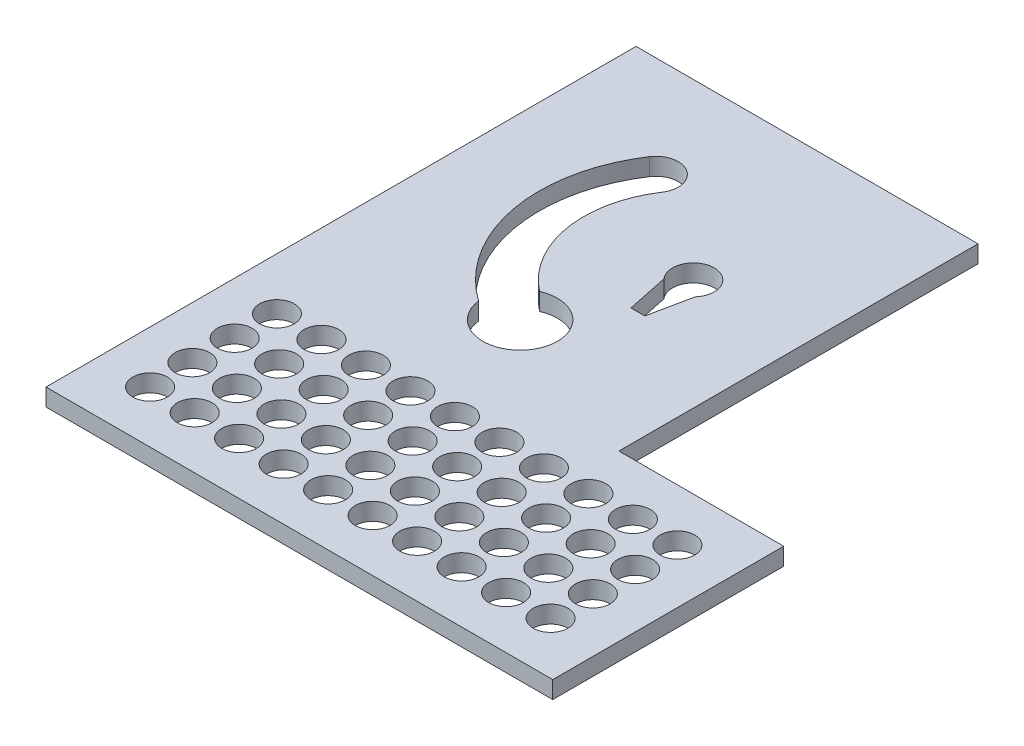
from build123d import *

# Parameters (mm, degrees)
Y_KSEKLIK_EKSTR_ZYON1_DEPTH = 2.5
IZIM2_R                     = 2.5
KES_EKSTR_ZYON1_DEPTH       = 3.5
KES_EKSTR_ZYON2_DEPTH       = 3.5
IZIM5_R                     = 2.5
KES_EKSTR_ZYON3_DEPTH       = 10


with BuildPart() as part:
    # Çizim1 → Yükseklik-Ekstrüzyon1 (new body)
    with BuildSketch(Plane(origin=(0, 0, 0), x_dir=(1, 0, 0), z_dir=(0, 1, 0))):
        Polygon((0, 85), (0, 0), (73, 0), (73, 33.274387234), (49.250000664, 33.280001445), (49.262226642, 85), align=None)
    extrude(amount=Y_KSEKLIK_EKSTR_ZYON1_DEPTH)

    # Çizim2 → Kes-Ekstrüzyon1 (cut, through all)
    with BuildSketch(Plane.XZ):
        with BuildLine():
            Line((32.262752909, -52), (31.012752909, -58.015686517))
            ThreePointArc((31.012752909, -58.015686517), (33.262752909, -63), (35.512752909, -58.015686517))
            Line((35.512752909, -58.015686517), (34.262752909, -52))
            Line((34.262752909, -52), (32.262752909, -52))
        make_face()
        with Locations((33.262752909, -60)):
            Circle(IZIM2_R, mode=Mode.SUBTRACT)
        with Locations((33.262752909, -60)):
            Circle(IZIM2_R)
    extrude(amount=-KES_EKSTR_ZYON1_DEPTH, mode=Mode.SUBTRACT)

    # Çizim3 → Kes-Ekstrüzyon2 (cut, through all)
    with BuildSketch(Plane.XZ):
        with BuildLine():
            ThreePointArc((23.625155421, -47.479747819), (21.093389501, -45.218251496), (20.421796506, -41.890614625))
            ThreePointArc((20.421796506, -41.890614625), (11.442928986, -55.909121855), (14.73399817, -72.228051677))
            ThreePointArc((14.73399817, -72.228051677), (19.167411707, -73.136261128), (20.075621158, -68.70284759))
            ThreePointArc((20.075621158, -68.70284759), (17.679202056, -57.393672541), (23.625155421, -47.479747819))
        make_face()
        with BuildLine():
            ThreePointArc((23.625155421, -47.479747819), (28.709149541, -47.037034129), (31.131753414, -42.545488503))
            ThreePointArc((31.131753414, -42.545488503), (26.084801903, -37.180508616), (20.421796506, -41.890614625))
            ThreePointArc((20.421796506, -41.890614625), (22.396967687, -40.640901066), (24.492585078, -39.605781304))
            ThreePointArc((24.492585078, -39.605781304), (28.696460613, -41.281320168), (27.02092175, -45.485195703))
            ThreePointArc((27.02092175, -45.485195703), (25.260651743, -46.376256868), (23.625155421, -47.479747819))
        make_face()
        with BuildLine():
            ThreePointArc((24.492585078, -39.605781304), (22.396967687, -40.640901066), (20.421796506, -41.890614625))
            ThreePointArc((20.421796506, -41.890614625), (21.093389501, -45.218251496), (23.625155421, -47.479747819))
            ThreePointArc((23.625155421, -47.479747819), (25.260651743, -46.376256868), (27.02092175, -45.485195703))
            ThreePointArc((27.02092175, -45.485195703), (28.696460613, -41.281320168), (24.492585078, -39.605781304))
        make_face()
    extrude(amount=-KES_EKSTR_ZYON2_DEPTH, mode=Mode.SUBTRACT)

    # Çizim5 → Kes-Ekstrüzyon3 (cut)
    with BuildSketch(Plane.XZ):
        with Locations((65.19, -7.5)):
            Circle(IZIM5_R)
        with Locations((58.78, -7.5)):
            Circle(IZIM5_R)
        with Locations((52.37, -7.5)):
            Circle(IZIM5_R)
        with Locations((45.96, -7.5)):
            Circle(IZIM5_R)
        with Locations((39.55, -7.5)):
            Circle(IZIM5_R)
        with Locations((33.14, -7.5)):
            Circle(IZIM5_R)
        with Locations((26.73, -7.5)):
            Circle(IZIM5_R)
        with Locations((20.32, -7.5)):
            Circle(IZIM5_R)
        with Locations((13.91, -7.5)):
            Circle(IZIM5_R)
        with Locations((7.5, -13.59)):
            Circle(IZIM5_R)
        with Locations((7.5, -19.68)):
            Circle(IZIM5_R)
        with Locations((7.5, -25.77)):
            Circle(IZIM5_R)
        with Locations((7.5, -7.5)):
            Circle(IZIM5_R)
        with Locations((13.91, -13.59)):
            Circle(IZIM5_R)
        with Locations((20.32, -13.59)):
            Circle(IZIM5_R)
        with Locations((26.73, -13.59)):
            Circle(IZIM5_R)
        with Locations((33.14, -13.59)):
            Circle(IZIM5_R)
        with Locations((39.55, -13.59)):
            Circle(IZIM5_R)
        with Locations((45.96, -13.59)):
            Circle(IZIM5_R)
        with Locations((52.37, -13.59)):
            Circle(IZIM5_R)
        with Locations((58.78, -13.59)):
            Circle(IZIM5_R)
        with Locations((65.19, -13.59)):
            Circle(IZIM5_R)
        with Locations((13.91, -19.68)):
            Circle(IZIM5_R)
        with Locations((20.32, -19.68)):
            Circle(IZIM5_R)
        with Locations((26.73, -19.68)):
            Circle(IZIM5_R)
        with Locations((33.14, -19.68)):
            Circle(IZIM5_R)
        with Locations((39.55, -19.68)):
            Circle(IZIM5_R)
        with Locations((45.96, -19.68)):
            Circle(IZIM5_R)
        with Locations((52.37, -19.68)):
            Circle(IZIM5_R)
        with Locations((58.78, -19.68)):
            Circle(IZIM5_R)
        with Locations((65.19, -19.68)):
            Circle(IZIM5_R)
        with Locations((13.91, -25.77)):
            Circle(IZIM5_R)
        with Locations((20.32, -25.77)):
            Circle(IZIM5_R)
        with Locations((26.73, -25.77)):
            Circle(IZIM5_R)
        with Locations((33.14, -25.77)):
            Circle(IZIM5_R)
        with Locations((39.55, -25.77)):
            Circle(IZIM5_R)
        with Locations((45.96, -25.77)):
            Circle(IZIM5_R)
        with Locations((52.37, -25.77)):
            Circle(IZIM5_R)
        with Locations((58.78, -25.77)):
            Circle(IZIM5_R)
        with Locations((65.19, -25.77)):
            Circle(IZIM5_R)
    extrude(amount=-KES_EKSTR_ZYON3_DEPTH, mode=Mode.SUBTRACT)


solid = part.part
